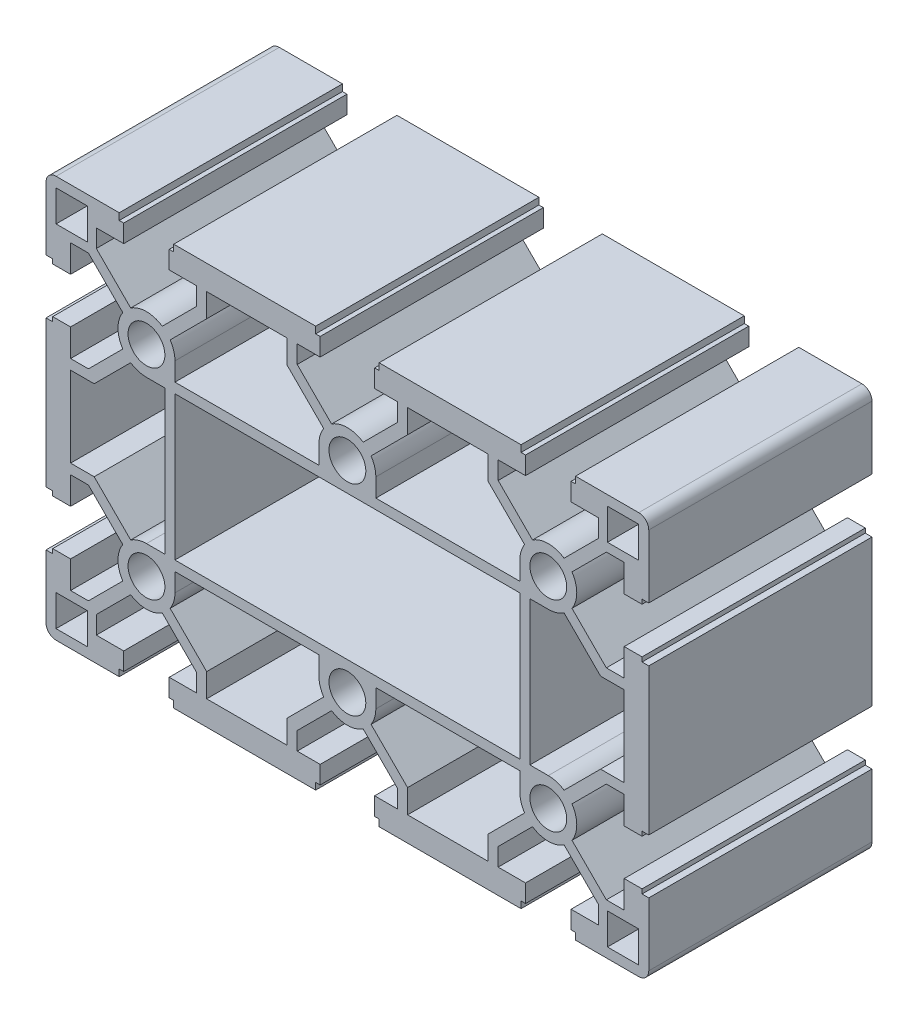
from build123d import *

# Parameters (mm, degrees)
IZIM1_R                     = 4.125
IZIM1_W                     = 7
IZIM1_H                     = 7
IZIM1_W_2                   = 77.25000006
IZIM1_H_2                   = 32.25000006
Y_KSEKLIK_EKSTR_ZYON1_DEPTH = 25


with BuildPart() as part:
    # Çizim1 → Yükseklik-Ekstrüzyon1 (new body, symmetric)
    with BuildSketch(Plane.XY):
        with BuildLine():
            Line((51.1, 45), (65.25, 45))
            ThreePointArc((65.25, 45), (66.840990258, 44.340990258), (67.5, 42.75))
            Line((67.5, 42.75), (67.5, 28.6))
            Line((67.5, 28.6), (66, 28.6))
            Line((66, 28.6), (66, 27.6))
            Line((66, 27.6), (62, 27.6))
            Line((62, 27.6), (62, 33.732233047))
            Line((62, 33.732233047), (58, 33.732233047))
            Line((58, 33.732233047), (50.304184632, 26.036417679))
            ThreePointArc((50.304184632, 26.036417679), (51.37499997, 22.499999991), (50.304184622, 18.963582306))
            Line((50.304184622, 18.963582306), (58, 11.267766886))
            Line((58, 11.267766886), (62, 11.267766886))
            Line((62, 11.267766886), (62, 17.4))
            Line((62, 17.4), (66, 17.4))
            Line((66, 17.4), (66, 16.4))
            Line((66, 16.4), (67.5, 16.4))
            Line((67.5, 16.4), (67.5, -16.4))
            Line((67.5, -16.4), (66, -16.4))
            Line((66, -16.4), (66, -17.4))
            Line((66, -17.4), (62, -17.4))
            Line((62, -17.4), (62, -11.267766886))
            Line((62, -11.267766886), (58, -11.267766886))
            Line((58, -11.267766886), (50.304184622, -18.963582306))
            ThreePointArc((50.304184622, -18.963582306), (51.37499997, -22.499999991), (50.304184632, -26.036417679))
            Line((50.304184632, -26.036417679), (58, -33.732233047))
            Line((58, -33.732233047), (62, -33.732233047))
            Line((62, -33.732233047), (62, -27.6))
            Line((62, -27.6), (66, -27.6))
            Line((66, -27.6), (66, -28.6))
            Line((66, -28.6), (67.5, -28.6))
            Line((67.5, -28.6), (67.5, -42.75))
            ThreePointArc((67.5, -42.75), (66.840990258, -44.340990258), (65.25, -45))
            Line((65.25, -45), (51.1, -45))
            Line((51.1, -45), (51.1, -43.5))
            Line((51.1, -43.5), (50.1, -43.5))
            Line((50.1, -43.5), (50.1, -39.5))
            Line((50.1, -39.5), (56.232233047, -39.5))
            Line((56.232233047, -39.5), (56.232233047, -35.5))
            Line((56.232233047, -35.5), (48.536417679, -27.804184632))
            ThreePointArc((48.536417679, -27.804184632), (45.000000009, -28.87499997), (41.463582336, -27.804184642))
            Line((41.463582336, -27.804184642), (33.767767019, -35.5))
            Line((33.767767019, -35.5), (33.76776702, -39.5))
            Line((33.76776702, -39.5), (39.900000067, -39.5))
            Line((39.900000067, -39.5), (39.900000067, -43.5))
            Line((39.900000067, -43.5), (38.900000067, -43.5))
            Line((38.900000067, -43.5), (38.900000067, -45))
            Line((38.900000067, -45), (7.1, -45))
            Line((7.1, -45), (7.1, -43.5))
            Line((7.1, -43.5), (6.1, -43.5))
            Line((6.1, -43.5), (6.1, -39.5))
            Line((6.1, -39.5), (11.23223298, -39.5))
            Line((11.23223298, -39.5), (11.232232981, -35.5))
            Line((11.232232981, -35.5), (3.536417664, -27.804184642))
            ThreePointArc((3.536417664, -27.804184642), (0, -28.87499997), (-3.536417664, -27.804184642))
            Line((-3.536417664, -27.804184642), (-11.232232981, -35.5))
            Line((-11.232232981, -35.5), (-11.23223298, -39.5))
            Line((-11.23223298, -39.5), (-6.1, -39.5))
            Line((-6.1, -39.5), (-6.1, -43.5))
            Line((-6.1, -43.5), (-7.1, -43.5))
            Line((-7.1, -43.5), (-7.1, -45))
            Line((-7.1, -45), (-38.900000067, -45))
            Line((-38.900000067, -45), (-38.900000067, -43.5))
            Line((-38.900000067, -43.5), (-39.900000067, -43.5))
            Line((-39.900000067, -43.5), (-39.900000067, -39.5))
            Line((-39.900000067, -39.5), (-33.76776702, -39.5))
            Line((-33.76776702, -39.5), (-33.767767019, -35.5))
            Line((-33.767767019, -35.5), (-41.463582336, -27.804184642))
            ThreePointArc((-41.463582336, -27.804184642), (-45.000000009, -28.87499997), (-48.536417679, -27.804184632))
            Line((-48.536417679, -27.804184632), (-56.232233047, -35.5))
            Line((-56.232233047, -35.5), (-56.232233047, -39.5))
            Line((-56.232233047, -39.5), (-50.1, -39.5))
            Line((-50.1, -39.5), (-50.1, -43.5))
            Line((-50.1, -43.5), (-51.1, -43.5))
            Line((-51.1, -43.5), (-51.1, -45))
            Line((-51.1, -45), (-65.25, -45))
            ThreePointArc((-65.25, -45), (-66.840990258, -44.340990258), (-67.5, -42.75))
            Line((-67.5, -42.75), (-67.5, -28.6))
            Line((-67.5, -28.6), (-66, -28.6))
            Line((-66, -28.6), (-66, -27.6))
            Line((-66, -27.6), (-62, -27.6))
            Line((-62, -27.6), (-62, -33.732233047))
            Line((-62, -33.732233047), (-58, -33.732233047))
            Line((-58, -33.732233047), (-50.304184632, -26.036417679))
            ThreePointArc((-50.304184632, -26.036417679), (-51.37499997, -22.499999991), (-50.304184622, -18.963582306))
            Line((-50.304184622, -18.963582306), (-58, -11.267766886))
            Line((-58, -11.267766886), (-62, -11.267766886))
            Line((-62, -11.267766886), (-62, -17.4))
            Line((-62, -17.4), (-66, -17.4))
            Line((-66, -17.4), (-66, -16.4))
            Line((-66, -16.4), (-67.5, -16.4))
            Line((-67.5, -16.4), (-67.5, 16.4))
            Line((-67.5, 16.4), (-66, 16.4))
            Line((-66, 16.4), (-66, 17.4))
            Line((-66, 17.4), (-62, 17.4))
            Line((-62, 17.4), (-62, 11.267766886))
            Line((-62, 11.267766886), (-58, 11.267766886))
            Line((-58, 11.267766886), (-50.304184622, 18.963582306))
            ThreePointArc((-50.304184622, 18.963582306), (-51.37499997, 22.499999991), (-50.304184632, 26.036417679))
            Line((-50.304184632, 26.036417679), (-58, 33.732233047))
            Line((-58, 33.732233047), (-62, 33.732233047))
            Line((-62, 33.732233047), (-62, 27.6))
            Line((-62, 27.6), (-66, 27.6))
            Line((-66, 27.6), (-66, 28.6))
            Line((-66, 28.6), (-67.5, 28.6))
            Line((-67.5, 28.6), (-67.5, 42.75))
            ThreePointArc((-67.5, 42.75), (-66.840990258, 44.340990258), (-65.25, 45))
            Line((-65.25, 45), (-51.1, 45))
            Line((-51.1, 45), (-51.1, 43.5))
            Line((-51.1, 43.5), (-50.1, 43.5))
            Line((-50.1, 43.5), (-50.1, 39.5))
            Line((-50.1, 39.5), (-56.232233047, 39.5))
            Line((-56.232233047, 39.5), (-56.232233047, 35.5))
            Line((-56.232233047, 35.5), (-48.536417679, 27.804184632))
            ThreePointArc((-48.536417679, 27.804184632), (-45.000000009, 28.87499997), (-41.463582336, 27.804184642))
            Line((-41.463582336, 27.804184642), (-33.767767019, 35.5))
            Line((-33.767767019, 35.5), (-33.76776702, 39.5))
            Line((-33.76776702, 39.5), (-39.900000067, 39.5))
            Line((-39.900000067, 39.5), (-39.900000067, 43.5))
            Line((-39.900000067, 43.5), (-38.900000067, 43.5))
            Line((-38.900000067, 43.5), (-38.900000067, 45))
            Line((-38.900000067, 45), (-7.1, 45))
            Line((-7.1, 45), (-7.1, 43.5))
            Line((-7.1, 43.5), (-6.1, 43.5))
            Line((-6.1, 43.5), (-6.1, 39.5))
            Line((-6.1, 39.5), (-11.23223298, 39.5))
            Line((-11.23223298, 39.5), (-11.232232981, 35.5))
            Line((-11.232232981, 35.5), (-3.536417664, 27.804184642))
            ThreePointArc((-3.536417664, 27.804184642), (0, 28.87499997), (3.536417664, 27.804184642))
            Line((3.536417664, 27.804184642), (11.232232981, 35.5))
            Line((11.232232981, 35.5), (11.23223298, 39.5))
            Line((11.23223298, 39.5), (6.1, 39.5))
            Line((6.1, 39.5), (6.1, 43.5))
            Line((6.1, 43.5), (7.1, 43.5))
            Line((7.1, 43.5), (7.1, 45))
            Line((7.1, 45), (38.900000067, 45))
            Line((38.900000067, 45), (38.900000067, 43.5))
            Line((38.900000067, 43.5), (39.900000067, 43.5))
            Line((39.900000067, 43.5), (39.900000067, 39.5))
            Line((39.900000067, 39.5), (33.76776702, 39.5))
            Line((33.76776702, 39.5), (33.767767019, 35.5))
            Line((33.767767019, 35.5), (41.463582336, 27.804184642))
            ThreePointArc((41.463582336, 27.804184642), (45.000000009, 28.87499997), (48.536417679, 27.804184632))
            Line((48.536417679, 27.804184632), (56.232233047, 35.5))
            Line((56.232233047, 35.5), (56.232233047, 39.5))
            Line((56.232233047, 39.5), (50.1, 39.5))
            Line((50.1, 39.5), (50.1, 43.5))
            Line((50.1, 43.5), (51.1, 43.5))
            Line((51.1, 43.5), (51.1, 45))
        make_face()
        with Locations((45, 22.5)):
            Circle(IZIM1_R, mode=Mode.SUBTRACT)
        with Locations((0, 22.5)):
            Circle(IZIM1_R, mode=Mode.SUBTRACT)
        with Locations((-45, 22.5)):
            Circle(IZIM1_R, mode=Mode.SUBTRACT)
        with Locations((-45, -22.5)):
            Circle(IZIM1_R, mode=Mode.SUBTRACT)
        with Locations((0, -22.5)):
            Circle(IZIM1_R, mode=Mode.SUBTRACT)
        with Locations((45, -22.5)):
            Circle(IZIM1_R, mode=Mode.SUBTRACT)
        with Locations((61.75, 39.25)):
            Rectangle(IZIM1_W, IZIM1_H, mode=Mode.SUBTRACT)
        with BuildLine():
            Line((56.714466092, 9.017766886), (62, 9.017766886))
            Line((62, 9.017766886), (62, -9.017766886))
            Line((62, -9.017766886), (56.714466092, -9.017766886))
            Line((56.714466092, -9.017766886), (48.536417665, -17.195815358))
            ThreePointArc((48.536417665, -17.195815358), (46.847491229, -16.398573874), (45, -16.12500003))
            Line((45, -16.12500003), (40.875, -16.12500003))
            Line((40.875, -16.12500003), (40.875, 16.12500003))
            Line((40.875, 16.12500003), (45, 16.12500003))
            ThreePointArc((45, 16.12500003), (46.847491229, 16.398573874), (48.536417665, 17.195815358))
            Line((48.536417665, 17.195815358), (56.714466092, 9.017766886))
        make_face(mode=Mode.SUBTRACT)
        with BuildLine():
            Line((31.517767019, 39.5), (13.482232981, 39.5))
            Line((13.482232981, 39.5), (13.482232981, 34.214466097))
            Line((13.482232981, 34.214466097), (5.304184622, 26.036417694))
            ThreePointArc((5.304184622, 26.036417694), (6.101426121, 24.347491246), (6.37499997, 22.5))
            Line((6.37499997, 22.5), (6.37499997, 18.375))
            Line((6.37499997, 18.375), (38.62500003, 18.375))
            Line((38.62500003, 18.375), (38.62500003, 22.5))
            ThreePointArc((38.62500003, 22.5), (38.898573879, 24.347491246), (39.695815378, 26.036417694))
            Line((39.695815378, 26.036417694), (31.517767019, 34.214466097))
            Line((31.517767019, 34.214466097), (31.517767019, 39.5))
        make_face(mode=Mode.SUBTRACT)
        Rectangle(IZIM1_W_2, IZIM1_H_2, mode=Mode.SUBTRACT)
        with BuildLine():
            Line((-6.37499997, 22.5), (-6.37499997, 18.375))
            Line((-6.37499997, 18.375), (-38.62500003, 18.375))
            Line((-38.62500003, 18.375), (-38.62500003, 22.5))
            ThreePointArc((-38.62500003, 22.5), (-38.898573879, 24.347491246), (-39.695815378, 26.036417694))
            Line((-39.695815378, 26.036417694), (-31.517767019, 34.214466097))
            Line((-31.517767019, 34.214466097), (-31.517767019, 39.5))
            Line((-31.517767019, 39.5), (-13.482232981, 39.5))
            Line((-13.482232981, 39.5), (-13.482232981, 34.214466097))
            Line((-13.482232981, 34.214466097), (-5.304184622, 26.036417694))
            ThreePointArc((-5.304184622, 26.036417694), (-6.101426121, 24.347491246), (-6.37499997, 22.5))
        make_face(mode=Mode.SUBTRACT)
        with BuildLine():
            Line((-40.875, 16.12500003), (-40.875, -16.12500003))
            Line((-40.875, -16.12500003), (-45, -16.12500003))
            ThreePointArc((-45, -16.12500003), (-46.847491229, -16.398573874), (-48.536417665, -17.195815358))
            Line((-48.536417665, -17.195815358), (-56.714466092, -9.017766886))
            Line((-56.714466092, -9.017766886), (-62, -9.017766886))
            Line((-62, -9.017766886), (-62, 9.017766886))
            Line((-62, 9.017766886), (-56.714466092, 9.017766886))
            Line((-56.714466092, 9.017766886), (-48.536417665, 17.195815358))
            ThreePointArc((-48.536417665, 17.195815358), (-46.847491229, 16.398573874), (-45, 16.12500003))
            Line((-45, 16.12500003), (-40.875, 16.12500003))
        make_face(mode=Mode.SUBTRACT)
        with Locations((-61.75, 39.25)):
            Rectangle(IZIM1_W, IZIM1_H, mode=Mode.SUBTRACT)
        with Locations((-61.75, -39.25)):
            Rectangle(IZIM1_W, IZIM1_H, mode=Mode.SUBTRACT)
        with BuildLine():
            Line((-31.517767019, -39.5), (-13.482232981, -39.5))
            Line((-13.482232981, -39.5), (-13.482232981, -34.214466097))
            Line((-13.482232981, -34.214466097), (-5.304184622, -26.036417694))
            ThreePointArc((-5.304184622, -26.036417694), (-6.101426121, -24.347491246), (-6.37499997, -22.5))
            Line((-6.37499997, -22.5), (-6.37499997, -18.375))
            Line((-6.37499997, -18.375), (-38.62500003, -18.375))
            Line((-38.62500003, -18.375), (-38.62500003, -22.5))
            ThreePointArc((-38.62500003, -22.5), (-38.898573879, -24.347491246), (-39.695815378, -26.036417694))
            Line((-39.695815378, -26.036417694), (-31.517767019, -34.214466097))
            Line((-31.517767019, -34.214466097), (-31.517767019, -39.5))
        make_face(mode=Mode.SUBTRACT)
        with BuildLine():
            Line((6.37499997, -22.5), (6.37499997, -18.375))
            Line((6.37499997, -18.375), (38.62500003, -18.375))
            Line((38.62500003, -18.375), (38.62500003, -22.5))
            ThreePointArc((38.62500003, -22.5), (38.898573879, -24.347491246), (39.695815378, -26.036417694))
            Line((39.695815378, -26.036417694), (31.517767019, -34.214466097))
            Line((31.517767019, -34.214466097), (31.517767019, -39.5))
            Line((31.517767019, -39.5), (13.482232981, -39.5))
            Line((13.482232981, -39.5), (13.482232981, -34.214466097))
            Line((13.482232981, -34.214466097), (5.304184622, -26.036417694))
            ThreePointArc((5.304184622, -26.036417694), (6.101426121, -24.347491246), (6.37499997, -22.5))
        make_face(mode=Mode.SUBTRACT)
        with Locations((61.75, -39.25)):
            Rectangle(IZIM1_W, IZIM1_H, mode=Mode.SUBTRACT)
    extrude(amount=Y_KSEKLIK_EKSTR_ZYON1_DEPTH, both=True)


solid = part.part
